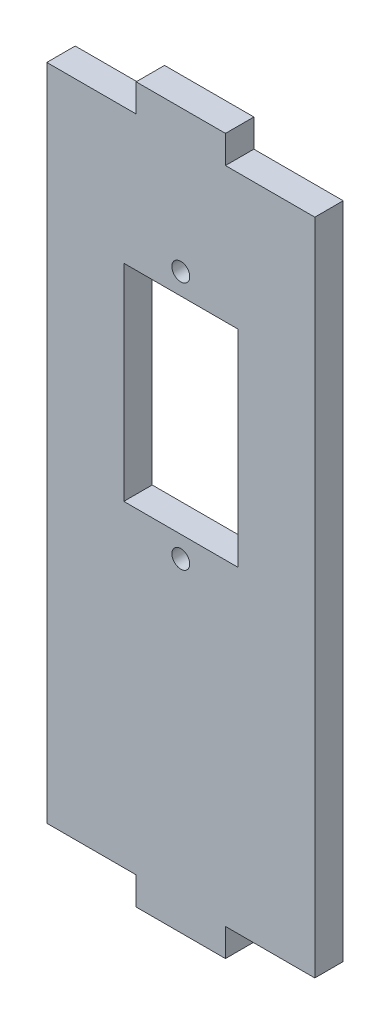
from build123d import *

# Parameters (mm, degrees)
SKETCH2_W               = 30
SKETCH2_H               = 80
BOSS_EXTRUDE1_DEPTH     = 3.18
SKETCH4_W               = 10
SKETCH4_H               = 3.12
CUT_EXTRUDE1_DEPTH      = 3.18
MIRROR2_COPY_1_SKETCH_W = 10
MIRROR2_COPY_1_SKETCH_H = 3.12
MIRROR2_COPY_1_DEPTH    = 3.18
SKETCH5_W               = 12.76
SKETCH5_H               = 23.091347567
CUT_EXTRUDE2_DEPTH      = 3.18
SKETCH6_R               = 1
CUT_EXTRUDE3_DEPTH      = 4.18


with BuildPart() as part:
    # Sketch2 → Boss-Extrude1 (new body)
    with BuildSketch(Plane.XY):
        Rectangle(SKETCH2_W, SKETCH2_H)
    extrude(amount=BOSS_EXTRUDE1_DEPTH)

    # Sketch4 → Cut-Extrude1 (cut)
    with BuildSketch(Plane.XY.offset(3.18)):
        with Locations((10, 38.44)):
            Rectangle(SKETCH4_W, SKETCH4_H)
    cut_extrude1 = extrude(amount=-CUT_EXTRUDE1_DEPTH, mode=Mode.SUBTRACT)

    # Mirror1: Cut-Extrude1 across plane
    add(cut_extrude1.mirror(Plane(origin=(0, 0, 0), x_dir=(0, 0, 1), z_dir=(1, 0, 0))), mode=Mode.SUBTRACT)

    # Mirror2: Cut-Extrude1 across plane
    add(cut_extrude1.mirror(Plane.ZX), mode=Mode.SUBTRACT)

    # Mirror2 copy 1 sketch → Mirror2 copy 1 (cut)
    with BuildSketch(Plane(origin=(0, 0, 3.18), x_dir=(-1, 0, 0), z_dir=(0, 0, 1))):
        with Locations((10, 38.44)):
            Rectangle(MIRROR2_COPY_1_SKETCH_W, MIRROR2_COPY_1_SKETCH_H)
    extrude(amount=-MIRROR2_COPY_1_DEPTH, mode=Mode.SUBTRACT)

    # Sketch5 → Cut-Extrude2 (cut)
    with BuildSketch(Plane(origin=(0, 0, 0), x_dir=(-1, 0, 0), z_dir=(0, 0, -1))):
        with Locations((0, 10.179687203)):
            Rectangle(SKETCH5_W, SKETCH5_H)
    extrude(amount=-CUT_EXTRUDE2_DEPTH, mode=Mode.SUBTRACT)

    # Sketch6 → Cut-Extrude3 (cut, through all)
    with BuildSketch(Plane(origin=(0, 0, 0), x_dir=(-1, 0, 0), z_dir=(0, 0, -1))):
        with Locations((0, 24.100360986)):
            Circle(SKETCH6_R)
        with Locations((0, -3.745986581)):
            Circle(SKETCH6_R)
    extrude(amount=-CUT_EXTRUDE3_DEPTH, mode=Mode.SUBTRACT)


solid = part.part
